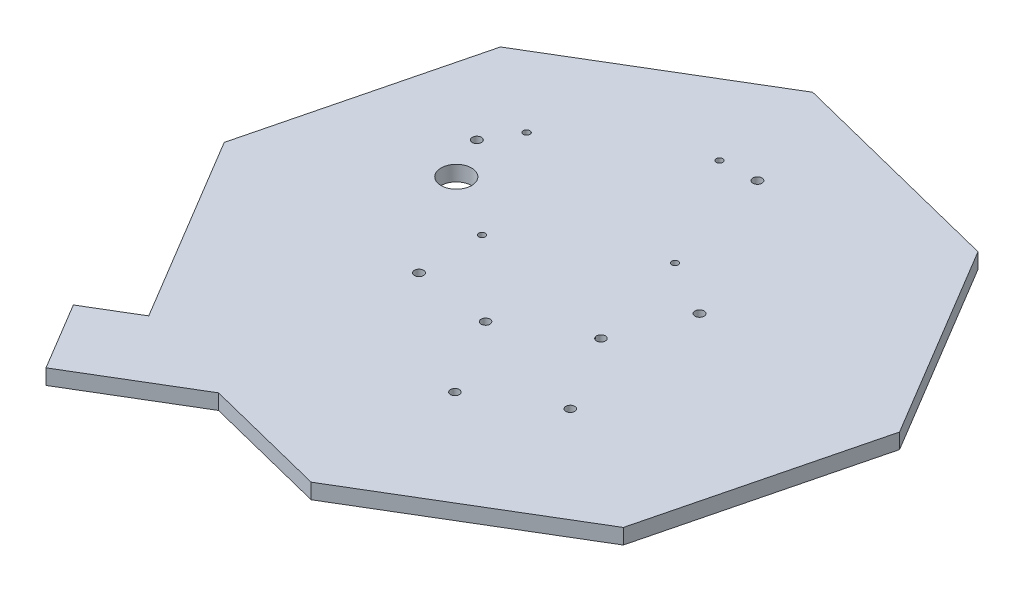
from build123d import *

# Parameters (mm, degrees)
BOSS_EXTRUDE2_DEPTH = 6.35
BOSS_EXTRUDE3_DEPTH = 6.35
SKETCH3_R           = 1.3716
CUT_EXTRUDE1_DEPTH  = 7.35
SKETCH4_R           = 6.35
CUT_EXTRUDE2_DEPTH  = 7.35
SKETCH5_R           = 1.905
CUT_EXTRUDE3_DEPTH  = 7.35
SKETCH7_R           = 1.85
CUT_EXTRUDE4_DEPTH  = 7.35


with BuildPart() as part:
    # Sketch1 → Boss-Extrude2 (new body)
    with BuildSketch(Plane(origin=(0, 0, 0), x_dir=(1, 0, 0), z_dir=(0, 1, 0))):
        Polygon((73.764977758, 99.321348004), (-18.071082704, 122.390514677), (-99.321348004, 73.764977758), (-122.390514677, -18.071082704), (-73.764977758, -99.321348004), (18.071082704, -122.390514677), (99.321348004, -73.764977758), (122.390514677, 18.071082704), align=None)
    extrude(amount=BOSS_EXTRUDE2_DEPTH)

    # Sketch2 → Boss-Extrude3 (add)
    with BuildSketch(Plane(origin=(0, 6.35, 0), x_dir=(-1, 0, 0), z_dir=(0, 1, 0))):
        Polygon((75.591082235, 96.270040344), (95.206631479, 108.009283415), (78.249947043, 136.342854545), (33.35213433, 109.473031516), (73.764977758, 99.321348004), align=None)
    extrude(amount=-BOSS_EXTRUDE3_DEPTH)

    # Sketch3 → Cut-Extrude1 (cut, through all)
    with BuildSketch(Plane.XZ):
        with Locations((-12.844640601, -78.437638464)):
            Circle(SKETCH3_R)
        with Locations((-35.416692023, -2.204063982)):
            Circle(SKETCH3_R)
        with Locations((-63.056087654, -48.387784923)):
            Circle(SKETCH3_R)
        with Locations((14.794755029, -32.253917523)):
            Circle(SKETCH3_R)
    extrude(amount=-CUT_EXTRUDE1_DEPTH, mode=Mode.SUBTRACT)

    # Sketch4 → Cut-Extrude2 (cut, through all)
    with BuildSketch(Plane.XZ):
        with Locations((-61.737440704, -17.814468138)):
            Circle(SKETCH4_R)
    extrude(amount=-CUT_EXTRUDE2_DEPTH, mode=Mode.SUBTRACT)

    # Sketch5 → Cut-Extrude3 (cut, through all)
    with BuildSketch(Plane.XZ):
        with Locations((2.267257691, -79.060054342)):
            Circle(SKETCH5_R)
        with Locations((-70.746175604, -35.363982912)):
            Circle(SKETCH5_R)
        with Locations((38.137167074, -19.123653876)):
            Circle(SKETCH5_R)
        with Locations((-34.876266221, 24.572417555)):
            Circle(SKETCH5_R)
    extrude(amount=-CUT_EXTRUDE3_DEPTH, mode=Mode.SUBTRACT)

    # Sketch7 → Cut-Extrude4 (cut, through all)
    with BuildSketch(Plane(origin=(0, 6.35, 0), x_dir=(1, 0, 0), z_dir=(0, 1, 0))):
        with Locations((15.538619902, -60.042079341)):
            Circle(SKETCH7_R)
        with Locations((-3.461904754, -28.29337759)):
            Circle(SKETCH7_R)
        with Locations((26.570650956, -10.319908322)):
            Circle(SKETCH7_R)
        with Locations((45.571175611, -42.068610072)):
            Circle(SKETCH7_R)
    extrude(amount=-CUT_EXTRUDE4_DEPTH, mode=Mode.SUBTRACT)


solid = part.part
